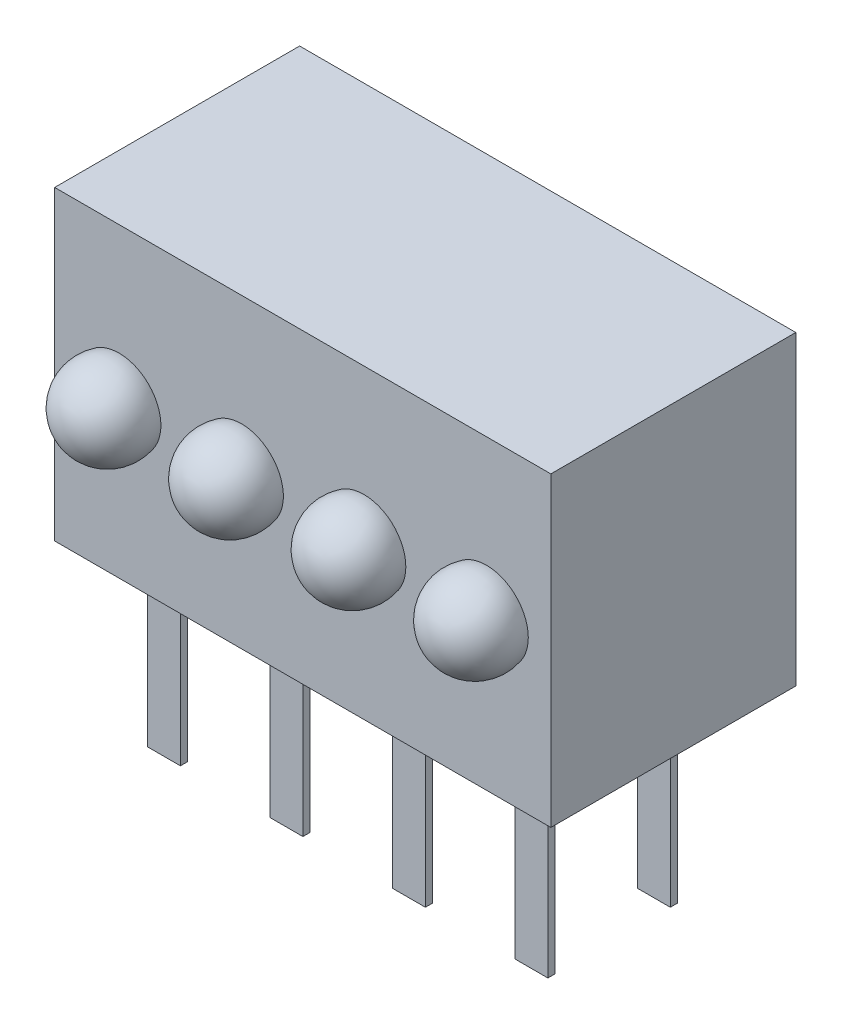
from build123d import *

# Parameters (mm, degrees)
SKETCH1_W          = 10.29
SKETCH1_H          = 5.08
EXTRUDE1_DEPTH     = 3.175
SKETCH2_W          = 0.686
SKETCH2_H          = 0.15
EXTRUDE2_DEPTH     = 3.68
SKETCH3_W          = 0.025316456
SKETCH3_H          = 0.026582278
CUT_EXTRUDE1_DEPTH = 0.01


with BuildPart() as part:
    # Sketch1 → Extrude1 (new body, symmetric)
    with BuildSketch(Plane(origin=(0, 0, 0), x_dir=(1, 0, 0), z_dir=(0, 1, 0))):
        Rectangle(SKETCH1_W, SKETCH1_H)
    extrude(amount=EXTRUDE1_DEPTH, both=True)

    # Sketch1_3 → Revolve1 (revolve)
    with BuildSketch(Plane(origin=(0, 0, 0), x_dir=(1, 0, 0), z_dir=(0, 1, 0)), mode=Mode.PRIVATE) as revolve1_sk:
        with BuildLine():
            Line((-2.942590062, -2.54), (-3.81, -2.54))
            Line((-3.81, -2.54), (-3.81, -3.68))
            ThreePointArc((-3.81, -3.68), (-3.093759817, -3.324977064), (-2.942590062, -2.54))
        make_face()
    revolve(revolve1_sk.sketch.rotate(Axis((-3.81, 0, 2.54), (0, 0, 1)), 180), axis=Axis((-3.81, 0, 2.54), (0, 0, 1)))  # turned: the seam where the file's is

    # Sketch1_4 → Revolve2 (revolve)
    with BuildSketch(Plane(origin=(0, 0, 0), x_dir=(1, 0, 0), z_dir=(0, 1, 0)), mode=Mode.PRIVATE) as revolve2_sk:
        with BuildLine():
            Line((-0.402590062, -2.54), (-1.27, -2.54))
            Line((-1.27, -2.54), (-1.27, -3.68))
            ThreePointArc((-1.27, -3.68), (-0.553759817, -3.324977064), (-0.402590062, -2.54))
        make_face()
    revolve(revolve2_sk.sketch.rotate(Axis((-1.27, 0, 2.54), (0, 0, 1)), 180), axis=Axis((-1.27, 0, 2.54), (0, 0, 1)))  # turned: the seam where the file's is

    # Sketch1_5 → Revolve3 (revolve)
    with BuildSketch(Plane(origin=(0, 0, 0), x_dir=(1, 0, 0), z_dir=(0, 1, 0))):
        with BuildLine():
            ThreePointArc((1.27, -3.68), (1.986240183, -3.324977064), (2.137409938, -2.54))
            Line((2.137409938, -2.54), (1.27, -2.54))
            Line((1.27, -2.54), (1.27, -3.68))
        make_face()
    revolve(axis=Axis((1.27, 0, 2.54), (0, 0, 1)))

    # Sketch1_6 → Revolve4 (revolve)
    with BuildSketch(Plane(origin=(0, 0, 0), x_dir=(1, 0, 0), z_dir=(0, 1, 0))):
        with BuildLine():
            ThreePointArc((3.81, -3.68), (4.526240183, -3.324977064), (4.677409938, -2.54))
            Line((4.677409938, -2.54), (3.81, -2.54))
            Line((3.81, -2.54), (3.81, -3.68))
        make_face()
    revolve(axis=Axis((3.81, 0, 2.54), (0, 0, 1)))

    # Sketch2 → Extrude2 (add)
    with BuildSketch(Plane.XZ.offset(3.175)):
        with Locations((-3.825, -1.02)):
            Rectangle(SKETCH2_W, SKETCH2_H)
        with Locations((-1.285, -1.02)):
            Rectangle(SKETCH2_W, SKETCH2_H)
        with Locations((1.255, -1.02)):
            Rectangle(SKETCH2_W, SKETCH2_H)
        with Locations((3.795, -1.02)):
            Rectangle(SKETCH2_W, SKETCH2_H)
        with Locations((3.795, 1.52)):
            Rectangle(SKETCH2_W, SKETCH2_H)
        with Locations((1.255, 1.52)):
            Rectangle(SKETCH2_W, SKETCH2_H)
        with Locations((-1.285, 1.52)):
            Rectangle(SKETCH2_W, SKETCH2_H)
        with Locations((-3.825, 1.52)):
            Rectangle(SKETCH2_W, SKETCH2_H)
    extrude(amount=EXTRUDE2_DEPTH)

    # Sketch3 → Cut-Extrude1 (cut)
    with BuildSketch(Plane.XZ.offset(3.175)):
        Polygon((-0.572151899, -1.949554214), (-0.595609177, -2.024237758), (-0.620352057, -2.024237758), (-0.636768196, -1.973901524), (-0.652294304, -2.024237758), (-0.678026108, -2.024237758), (-0.701265823, -1.949554214), (-0.676087816, -1.949554214), (-0.663093354, -2.0010376), (-0.646677215, -1.949554214), (-0.625178006, -1.949554214), (-0.608860759, -2.0010376), (-0.596044304, -1.949554214), align=None)
        Polygon((-0.437974684, -1.949554214), (-0.461431962, -2.024237758), (-0.486174842, -2.024237758), (-0.502590981, -1.973901524), (-0.518117089, -2.024237758), (-0.543848892, -2.024237758), (-0.567088608, -1.949554214), (-0.541910601, -1.949554214), (-0.528916139, -2.0010376), (-0.5125, -1.949554214), (-0.491000791, -1.949554214), (-0.474683544, -2.0010376), (-0.461867089, -1.949554214), align=None)
        Polygon((-0.303797468, -1.949554214), (-0.327254747, -2.024237758), (-0.351997627, -2.024237758), (-0.368413766, -1.973901524), (-0.383939873, -2.024237758), (-0.409671677, -2.024237758), (-0.432911392, -1.949554214), (-0.407733386, -1.949554214), (-0.394738924, -2.0010376), (-0.378322785, -1.949554214), (-0.356823576, -1.949554214), (-0.340506329, -2.0010376), (-0.327689873, -1.949554214), align=None)
        with Locations((-0.275949367, -2.010946619)):
            Rectangle(SKETCH3_W, SKETCH3_H)
        with BuildLine():
            add(Edge.make_bspline(
                [(-0.159493671, -1.993066872), (-0.15953016, -1.994289014), (-0.159601812, -1.996688892), (-0.16021153, -2.00019647), (-0.161205016, -2.003521175), (-0.162579134, -2.006683836), (-0.164367936, -2.009662454), (-0.166577526, -2.012442731), (-0.169141939, -2.015077531), (-0.172108149, -2.017483662), (-0.175388259, -2.019688038), (-0.178985835, -2.021585037), (-0.182864539, -2.02318152), (-0.187013125, -2.024520072), (-0.191459564, -2.025508652), (-0.196177094, -2.026232598), (-0.201170512, -2.026705927), (-0.20459409, -2.026747894), (-0.206348892, -2.026769404)],
                knots=[0, 0, 0, 0, 0.907352243, 1.781736951, 2.63548328, 3.47985091, 4.336556021, 5.208523475, 6.112432747, 7.062451073, 8.040435374, 9.043840564, 10.077958095, 11.152835584, 12.277940427, 13.457536469, 14.696825396, 16, 16, 16, 16], degree=3))
            add(Edge.make_bspline(
                [(-0.206348892, -2.026769404), (-0.208367148, -2.026745332), (-0.21227633, -2.026698708), (-0.217939855, -2.026270109), (-0.223207892, -2.025623969), (-0.228103607, -2.024657427), (-0.232708206, -2.023456662), (-0.237141474, -2.022165371), (-0.241422786, -2.020700955), (-0.244195876, -2.019600797), (-0.24556962, -2.019055796)],
                knots=[0, 0, 0, 0, 1.203215828, 2.33052265, 3.384689099, 4.366106119, 5.303329643, 6.221311756, 7.118865988, 8, 8, 8, 8], degree=3))
            Line((-0.24556962, -2.019055796), (-0.24556962, -1.995123834))
            Line((-0.24556962, -1.995123834), (-0.242721519, -1.995123834))
            add(Edge.make_bspline(
                [(-0.242721519, -1.995123834), (-0.241356205, -1.996205289), (-0.238633592, -1.99836185), (-0.234200359, -2.001124455), (-0.229552713, -2.003526618), (-0.224707243, -2.00550062), (-0.219810398, -2.007086944), (-0.21493502, -2.008180472), (-0.210169433, -2.008927821), (-0.207010864, -2.009008327), (-0.205458861, -2.009047885)],
                knots=[0, 0, 0, 0, 1.030622468, 2.055194264, 3.087043286, 4.125157485, 5.149848264, 6.130935704, 7.081611712, 8, 8, 8, 8], degree=3))
            add(Edge.make_bspline(
                [(-0.205458861, -2.009047885), (-0.205030085, -2.009046961), (-0.204112108, -2.009044984), (-0.202650581, -2.008917257), (-0.20099877, -2.00882168), (-0.199226261, -2.008614496), (-0.197429535, -2.008392635), (-0.195767134, -2.00801771), (-0.194257539, -2.007652843), (-0.193351018, -2.007284846), (-0.192919304, -2.007109594)],
                knots=[0, 0, 0, 0, 0.806402781, 1.726445712, 2.758724871, 3.919014682, 5.083870887, 6.16165551, 7.124521387, 8, 8, 8, 8], degree=3))
            add(Edge.make_bspline(
                [(-0.192919304, -2.007109594), (-0.192439741, -2.006881452), (-0.191497298, -2.006433105), (-0.190203698, -2.005622786), (-0.189036018, -2.004739321), (-0.187978647, -2.00377439), (-0.187104366, -2.00260864), (-0.186480499, -2.001199968), (-0.186135606, -1.99955095), (-0.186096583, -1.998375747), (-0.186075949, -1.997754372)],
                knots=[0, 0, 0, 0, 1.024747072, 2.013846092, 2.940605744, 3.850156746, 4.769278501, 5.73222711, 6.800942666, 8, 8, 8, 8], degree=3))
            add(Edge.make_bspline(
                [(-0.186075949, -1.997754372), (-0.186107794, -1.997208735), (-0.18617041, -1.996135851), (-0.186747603, -1.994600737), (-0.187657041, -1.993191568), (-0.188938631, -1.991922794), (-0.190531807, -1.99077326), (-0.192474191, -1.989790955), (-0.194724312, -1.988917767), (-0.196368382, -1.988499789), (-0.197231013, -1.98828048)],
                knots=[0, 0, 0, 0, 0.82557554, 1.623324704, 2.456147571, 3.35491006, 4.343819762, 5.427079081, 6.650009487, 8, 8, 8, 8], degree=3))
            add(Edge.make_bspline(
                [(-0.197231013, -1.98828048), (-0.199199639, -1.98783224), (-0.203238649, -1.986912589), (-0.209388473, -1.985773835), (-0.215516824, -1.984498975), (-0.219469591, -1.983292332), (-0.221400316, -1.982702948)],
                knots=[0, 0, 0, 0, 0.976100998, 2.002656142, 3.024398856, 4, 4, 4, 4], degree=3))
            add(Edge.make_bspline(
                [(-0.221400316, -1.982702948), (-0.222438835, -1.982349958), (-0.224460408, -1.98166283), (-0.227351919, -1.98050117), (-0.230013147, -1.979231341), (-0.23245286, -1.977875786), (-0.234653549, -1.976403246), (-0.236647817, -1.974861868), (-0.238410933, -1.973221828), (-0.239957738, -1.971482062), (-0.241282641, -1.969631359), (-0.242435025, -1.967686162), (-0.243417646, -1.965630742), (-0.244195684, -1.963460519), (-0.244820323, -1.961186864), (-0.245239305, -1.958809152), (-0.245538322, -1.956326023), (-0.245559046, -1.954631638), (-0.24556962, -1.953767031)],
                knots=[0, 0, 0, 0, 1.287047841, 2.5053592, 3.654260482, 4.74538952, 5.777514103, 6.75871007, 7.700244599, 8.599107454, 9.48590269, 10.366941872, 11.24940663, 12.154970331, 13.068988358, 14.012872203, 14.986013017, 16, 16, 16, 16], degree=3))
            add(Edge.make_bspline(
                [(-0.24556962, -1.953767031), (-0.245532318, -1.952610886), (-0.245458909, -1.950335614), (-0.24485748, -1.947006569), (-0.24383089, -1.943857833), (-0.242444827, -1.94085437), (-0.240616199, -1.938041284), (-0.238431404, -1.935362736), (-0.235807357, -1.932891145), (-0.232830235, -1.930590811), (-0.229542851, -1.928511412), (-0.226003867, -1.926680856), (-0.222234578, -1.925144205), (-0.218249032, -1.923870311), (-0.214030563, -1.92291564), (-0.20959333, -1.922196708), (-0.204919541, -1.921783526), (-0.20172812, -1.921732276), (-0.200098892, -1.921706113)],
                knots=[0, 0, 0, 0, 0.894990994, 1.761326291, 2.609044902, 3.454222546, 4.315366365, 5.200560057, 6.125081389, 7.100429509, 8.110379559, 9.133447974, 10.182136699, 11.259192205, 12.370181258, 13.528580438, 14.738335141, 16, 16, 16, 16], degree=3))
            add(Edge.make_bspline(
                [(-0.200098892, -1.921706113), (-0.198430198, -1.921728266), (-0.19509564, -1.921772534), (-0.1901143, -1.922151091), (-0.185159872, -1.922703402), (-0.180297448, -1.923552643), (-0.175605285, -1.924520875), (-0.17118617, -1.925620148), (-0.167106618, -1.926857654), (-0.164532965, -1.927812056), (-0.163291139, -1.928272569)],
                knots=[0, 0, 0, 0, 1.065407564, 2.129008667, 3.188544425, 4.247469455, 5.279542408, 6.247502114, 7.154394069, 8, 8, 8, 8], degree=3))
            Line((-0.163291139, -1.928272569), (-0.163291139, -1.950820037))
            Line((-0.163291139, -1.950820037), (-0.166119462, -1.950820037))
            add(Edge.make_bspline(
                [(-0.166119462, -1.950820037), (-0.167192966, -1.950020749), (-0.169383743, -1.948389584), (-0.173033347, -1.946287848), (-0.177000967, -1.944347757), (-0.181282594, -1.9426561), (-0.185742374, -1.941198093), (-0.190325133, -1.940178535), (-0.194951348, -1.939536827), (-0.198053052, -1.939464038), (-0.19960443, -1.939427632)],
                knots=[0, 0, 0, 0, 0.892265782, 1.820912499, 2.804518821, 3.836954028, 4.889985052, 5.931488012, 6.965393252, 8, 8, 8, 8], degree=3))
            add(Edge.make_bspline(
                [(-0.19960443, -1.939427632), (-0.200700035, -1.939449534), (-0.202897679, -1.939493468), (-0.20616687, -1.939878354), (-0.209407348, -1.940517207), (-0.21144203, -1.941333258), (-0.212460443, -1.941741714)],
                knots=[0, 0, 0, 0, 0.999122297, 2.004111588, 3.001004448, 4, 4, 4, 4], degree=3))
            add(Edge.make_bspline(
                [(-0.212460443, -1.941741714), (-0.212894173, -1.941942893), (-0.213761342, -1.942345117), (-0.214968884, -1.943124742), (-0.216089856, -1.944041086), (-0.217085439, -1.945093843), (-0.217929873, -1.946262197), (-0.218548899, -1.947529779), (-0.218923392, -1.948893661), (-0.218965739, -1.94982876), (-0.218987342, -1.950305796)],
                knots=[0, 0, 0, 0, 1.004925302, 2.009180302, 3.014392739, 4.04465309, 5.049195417, 6.035570224, 6.99785458, 8, 8, 8, 8], degree=3))
            add(Edge.make_bspline(
                [(-0.218987342, -1.950305796), (-0.218952904, -1.950943962), (-0.218887095, -1.952163437), (-0.218280511, -1.953879233), (-0.217295678, -1.955357667), (-0.216135073, -1.956352587), (-0.215017943, -1.957050025), (-0.213982284, -1.957560536), (-0.212773057, -1.958043895), (-0.211401809, -1.958541363), (-0.209865482, -1.959032551), (-0.208156925, -1.959508097), (-0.206274208, -1.959957393), (-0.204958333, -1.960243584), (-0.204272152, -1.960392822)],
                knots=[0, 0, 0, 0, 1.173816843, 2.243057204, 3.312297565, 4.415174738, 5.03266065, 5.73970059, 6.541434878, 7.433956553, 8.430083051, 9.515931566, 10.70464786, 12, 12, 12, 12], degree=3))
            add(Edge.make_bspline(
                [(-0.204272152, -1.960392822), (-0.202439229, -1.960768266), (-0.198844263, -1.961504637), (-0.193445039, -1.962617003), (-0.187940051, -1.963882362), (-0.184268899, -1.965034358), (-0.182357595, -1.965634119)],
                knots=[0, 0, 0, 0, 0.995749986, 1.952994291, 2.934271555, 4, 4, 4, 4], degree=3))
            add(Edge.make_bspline(
                [(-0.182357595, -1.965634119), (-0.181411107, -1.965953478), (-0.179559623, -1.966578196), (-0.176918075, -1.96766288), (-0.174469022, -1.968844969), (-0.172190751, -1.970067455), (-0.17012867, -1.971430672), (-0.168235447, -1.972845319), (-0.166552428, -1.974373428), (-0.165054478, -1.975986286), (-0.163736077, -1.977696718), (-0.162601114, -1.979534821), (-0.161637968, -1.98148935), (-0.160829836, -1.983562422), (-0.16025182, -1.98576949), (-0.159817762, -1.98809579), (-0.15952694, -1.990541106), (-0.159504884, -1.992215552), (-0.159493671, -1.993066872)],
                knots=[0, 0, 0, 0, 1.237386967, 2.420528625, 3.534815053, 4.605870898, 5.620827102, 6.594482803, 7.531295079, 8.432978826, 9.318460435, 10.202471551, 11.10474705, 12.014900263, 12.954095338, 13.926516828, 14.945802342, 16, 16, 16, 16], degree=3))
        make_face()
        with BuildLine():
            Line((-0.067088608, -2.024237758), (-0.091139241, -2.024237758))
            Line((-0.091139241, -2.024237758), (-0.091139241, -2.01640548))
            add(Edge.make_bspline(
                [(-0.091139241, -2.01640548), (-0.092232496, -2.017214147), (-0.094340276, -2.018773246), (-0.097514015, -2.02085201), (-0.100542736, -2.022635172), (-0.103464337, -2.024177325), (-0.106479693, -2.025368172), (-0.109707195, -2.026190028), (-0.113209459, -2.026691148), (-0.115636434, -2.026742739), (-0.116890823, -2.026769404)],
                knots=[0, 0, 0, 0, 1.150906677, 2.218931226, 3.20955724, 4.125565256, 5.012676028, 5.946647191, 6.938718366, 8, 8, 8, 8], degree=3))
            add(Edge.make_bspline(
                [(-0.116890823, -2.026769404), (-0.117907168, -2.026746675), (-0.119886286, -2.026702415), (-0.122763616, -2.026357677), (-0.125470927, -2.025819531), (-0.127987077, -2.025013675), (-0.130352422, -2.024039558), (-0.132503941, -2.022780471), (-0.13449163, -2.021321134), (-0.136295007, -2.019644198), (-0.137885627, -2.017723236), (-0.139272677, -2.015600485), (-0.140448489, -2.013265847), (-0.141390127, -2.01071448), (-0.142145061, -2.007956036), (-0.142669038, -2.004976829), (-0.142989618, -2.00178969), (-0.143021559, -1.999594561), (-0.143037975, -1.998466398)],
                knots=[0, 0, 0, 0, 1.108935798, 2.159418225, 3.158520219, 4.116592843, 5.038730546, 5.944611115, 6.829677354, 7.725673622, 8.624842385, 9.544872214, 10.487719724, 11.471363217, 12.50822837, 13.604887271, 14.769056852, 16, 16, 16, 16], degree=3))
            Line((-0.143037975, -1.998466398), (-0.143037975, -1.949554214))
            Line((-0.143037975, -1.949554214), (-0.118987342, -1.949554214))
            Line((-0.118987342, -1.949554214), (-0.118987342, -1.987133328))
            add(Edge.make_bspline(
                [(-0.118987342, -1.987133328), (-0.118985706, -1.988049799), (-0.118982576, -1.989804015), (-0.118900237, -1.992309821), (-0.118779336, -1.994577994), (-0.118640631, -1.996620022), (-0.118387615, -1.998466773), (-0.118009906, -2.000132934), (-0.11753908, -2.001652536), (-0.117074761, -2.002559238), (-0.116851266, -2.00299567)],
                knots=[0, 0, 0, 0, 1.361401701, 2.605856924, 3.723918663, 4.735739235, 5.645738665, 6.489217889, 7.27279937, 8, 8, 8, 8], degree=3))
            add(Edge.make_bspline(
                [(-0.116851266, -2.00299567), (-0.116621226, -2.003394318), (-0.116168987, -2.004178025), (-0.115249176, -2.005185173), (-0.114173193, -2.006022079), (-0.112903555, -2.006694723), (-0.111410474, -2.007178427), (-0.109678473, -2.007525174), (-0.107692458, -2.007738997), (-0.106283538, -2.007767159), (-0.105537975, -2.007782062)],
                knots=[0, 0, 0, 0, 0.849057291, 1.669173542, 2.503217716, 3.359509317, 4.311793648, 5.394940091, 6.621469141, 8, 8, 8, 8], degree=3))
            add(Edge.make_bspline(
                [(-0.105537975, -2.007782062), (-0.10499671, -2.007764605), (-0.103883832, -2.007728711), (-0.102178621, -2.007498783), (-0.100389592, -2.007137127), (-0.097875395, -2.006478103), (-0.09469925, -2.005298925), (-0.092335111, -2.003940123), (-0.091139241, -2.00325279)],
                knots=[0, 0, 0, 0, 0.638164724, 1.312110757, 2.025558264, 2.789159289, 4.375836335, 6, 6, 6, 6], degree=3))
            Line((-0.091139241, -2.00325279), (-0.091139241, -1.949554214))
            Line((-0.091139241, -1.949554214), (-0.067088608, -1.949554214))
            Line((-0.067088608, -1.949554214), (-0.067088608, -2.024237758))
        make_face()
        with BuildLine():
            Line((0.030379747, -2.024237758), (0.006329114, -2.024237758))
            Line((0.006329114, -2.024237758), (0.006329114, -1.986658645))
            add(Edge.make_bspline(
                [(0.006329114, -1.986658645), (0.00630879, -1.985128171), (0.006268255, -1.982075759), (0.005934675, -1.978318983), (0.005600966, -1.975471193), (0.005224143, -1.973635126), (0.004793956, -1.97208679), (0.00438151, -1.971201052), (0.004193038, -1.970796303)],
                knots=[0, 0, 0, 0, 1.709235885, 3.408940626, 4.211008593, 4.910095588, 5.501954032, 6, 6, 6, 6], degree=3))
            add(Edge.make_bspline(
                [(0.004193038, -1.970796303), (0.00394861, -1.97039818), (0.003469373, -1.969617605), (0.002531558, -1.968605583), (0.001434909, -1.967769369), (0.000156185, -1.96710442), (-0.001328468, -1.966618522), (-0.003041142, -1.966231863), (-0.005027113, -1.966063302), (-0.006434481, -1.966028393), (-0.007179589, -1.96600991)],
                knots=[0, 0, 0, 0, 0.860145871, 1.686437142, 2.528070002, 3.393017362, 4.331453407, 5.402595683, 6.624848233, 8, 8, 8, 8], degree=3))
            add(Edge.make_bspline(
                [(-0.007179589, -1.96600991), (-0.008311478, -1.966066491), (-0.010622712, -1.966182024), (-0.013484003, -1.966895615), (-0.015810878, -1.967707913), (-0.017656499, -1.968482149), (-0.019573028, -1.969436775), (-0.020856452, -1.970163849), (-0.021518987, -1.970539182)],
                knots=[0, 0, 0, 0, 1.338419466, 2.732951426, 3.468143565, 4.254837763, 5.099104234, 6, 6, 6, 6], degree=3))
            Line((-0.021518987, -1.970539182), (-0.021518987, -2.024237758))
            Line((-0.021518987, -2.024237758), (-0.04556962, -2.024237758))
            Line((-0.04556962, -2.024237758), (-0.04556962, -1.949554214))
            Line((-0.04556962, -1.949554214), (-0.021518987, -1.949554214))
            Line((-0.021518987, -1.949554214), (-0.021518987, -1.957386493))
            add(Edge.make_bspline(
                [(-0.021518987, -1.957386493), (-0.02046175, -1.956580055), (-0.018403774, -1.955010276), (-0.015227022, -1.952976866), (-0.01215631, -1.95116701), (-0.009101788, -1.949654875), (-0.005977291, -1.948456275), (-0.00270966, -1.947640672), (0.000707053, -1.947097724), (0.003043726, -1.947047912), (0.004232595, -1.947022569)],
                knots=[0, 0, 0, 0, 1.126064518, 2.191951536, 3.19307265, 4.144813015, 5.076393104, 6.021983703, 6.993610568, 8, 8, 8, 8], degree=3))
            add(Edge.make_bspline(
                [(0.004232595, -1.947022569), (0.005228866, -1.947047958), (0.007173765, -1.947097521), (0.010008526, -1.947407231), (0.012679947, -1.947957895), (0.015172222, -1.948755725), (0.017514838, -1.949741338), (0.019676795, -1.950972848), (0.021668821, -1.952431288), (0.02349739, -1.954092229), (0.025127571, -1.955982187), (0.026547057, -1.95809856), (0.02771848, -1.960447289), (0.028727312, -1.962994425), (0.029461537, -1.965772196), (0.029987988, -1.968762962), (0.030338418, -1.971968144), (0.030365695, -1.974184044), (0.030379747, -1.975325575)],
                knots=[0, 0, 0, 0, 1.088441561, 2.124831547, 3.110816719, 4.062969431, 4.979391633, 5.88258537, 6.774334107, 7.671621258, 8.575503974, 9.49441354, 10.447872957, 11.437639084, 12.482478955, 13.580222388, 14.753440527, 16, 16, 16, 16], degree=3))
            Line((0.030379747, -1.975325575), (0.030379747, -2.024237758))
        make_face()
        Polygon((0.125316456, -2.024237758), (0.053164557, -2.024237758), (0.053164557, -1.924237758), (0.078481013, -1.924237758), (0.078481013, -2.005250417), (0.125316456, -2.005250417), align=None)
        Polygon((0.212658228, -2.024237758), (0.140506329, -2.024237758), (0.140506329, -1.924237758), (0.212658228, -1.924237758), (0.212658228, -1.9432251), (0.165822785, -1.9432251), (0.165822785, -1.960946619), (0.208860759, -1.960946619), (0.208860759, -1.979933961), (0.165822785, -1.979933961), (0.165822785, -2.005250417), (0.212658228, -2.005250417), align=None)
        with BuildLine():
            add(Edge.make_bspline(
                [(0.329113924, -1.974336651), (0.329094609, -1.97548434), (0.329056357, -1.977757226), (0.328761165, -1.981122032), (0.32823514, -1.984387708), (0.327555959, -1.987571956), (0.326633453, -1.990650884), (0.325551739, -1.993658461), (0.324242093, -1.996563955), (0.322737241, -1.999365389), (0.321087768, -2.002037492), (0.319313019, -2.004557701), (0.31746724, -2.006940919), (0.315477927, -2.009135813), (0.313398746, -2.011177832), (0.311223217, -2.013068646), (0.308918153, -2.014772077), (0.30731099, -2.015794961), (0.30650712, -2.016306588)],
                knots=[0, 0, 0, 0, 1.105570398, 2.18947457, 3.250358341, 4.290584537, 5.323553275, 6.344225964, 7.367641686, 8.3905646, 9.405808457, 10.390761353, 11.358902336, 12.307789878, 13.241960776, 14.165076779, 15.082208636, 16, 16, 16, 16], degree=3))
            add(Edge.make_bspline(
                [(0.30650712, -2.016306588), (0.305267899, -2.017018757), (0.302783134, -2.018446731), (0.298799188, -2.020114862), (0.294668069, -2.021522818), (0.290309515, -2.022571008), (0.285663167, -2.023299741), (0.28066851, -2.023862791), (0.275267382, -2.024163156), (0.2715325, -2.024212324), (0.269600475, -2.024237758)],
                knots=[0, 0, 0, 0, 0.896298978, 1.797171328, 2.70531317, 3.633678302, 4.606491125, 5.655688921, 6.787306437, 8, 8, 8, 8], degree=3))
            Line((0.269600475, -2.024237758), (0.234177215, -2.024237758))
            Line((0.234177215, -2.024237758), (0.234177215, -1.924237758))
            Line((0.234177215, -1.924237758), (0.270609177, -1.924237758))
            add(Edge.make_bspline(
                [(0.270609177, -1.924237758), (0.272587901, -1.924254454), (0.276404614, -1.924286657), (0.281915032, -1.924702626), (0.287013411, -1.925302145), (0.291697991, -1.926228837), (0.296006397, -1.927337488), (0.299937419, -1.928700524), (0.303549308, -1.930198796), (0.305728136, -1.931472544), (0.306784019, -1.932089815)],
                knots=[0, 0, 0, 0, 1.267192274, 2.444256634, 3.537982003, 4.553396635, 5.500903572, 6.385021601, 7.217363933, 8, 8, 8, 8], degree=3))
            add(Edge.make_bspline(
                [(0.306784019, -1.932089815), (0.307634972, -1.932626356), (0.309327097, -1.933693269), (0.311728312, -1.935475122), (0.313957739, -1.937431199), (0.316086242, -1.939483017), (0.318066056, -1.941685905), (0.319909269, -1.944024609), (0.321613036, -1.946502716), (0.323171192, -1.949112135), (0.324591277, -1.951842375), (0.325783356, -1.954714721), (0.326822718, -1.957697594), (0.327668801, -1.960796533), (0.32832513, -1.964013923), (0.328771214, -1.967351403), (0.329054647, -1.970804592), (0.329093999, -1.973149385), (0.329113924, -1.974336651)],
                knots=[0, 0, 0, 0, 0.964043478, 1.917004671, 2.862223898, 3.805158963, 4.749279098, 5.698713747, 6.657523689, 7.629652222, 8.610369353, 9.604453025, 10.607693792, 11.636365947, 12.681120053, 13.752669011, 14.862083412, 16, 16, 16, 16], degree=3))
        make_face()
        with BuildLine():
            add(Edge.make_bspline(
                [(0.302531646, -1.974178423), (0.302521175, -1.97337371), (0.302500636, -1.971795218), (0.302312313, -1.969479042), (0.302041725, -1.967252993), (0.301652591, -1.96510936), (0.301112159, -1.963059212), (0.300479977, -1.961097643), (0.299752887, -1.959218719), (0.298871957, -1.95744106), (0.297898133, -1.955732723), (0.296750689, -1.954147195), (0.295502338, -1.952634313), (0.294124055, -1.951206327), (0.292581114, -1.949900431), (0.290921012, -1.948670355), (0.289120654, -1.947542029), (0.287847665, -1.946881979), (0.287203323, -1.946547885)],
                knots=[0, 0, 0, 0, 1.152052275, 2.259818351, 3.325348653, 4.362224493, 5.376551665, 6.358740615, 7.312387502, 8.258104984, 9.197203025, 10.124507262, 11.056413058, 12.004389423, 12.961766972, 13.947352551, 14.961020569, 16, 16, 16, 16], degree=3))
            add(Edge.make_bspline(
                [(0.287203323, -1.946547885), (0.286528425, -1.946241173), (0.285190731, -1.945633248), (0.283119908, -1.944902056), (0.281030524, -1.94432922), (0.278828925, -1.943898362), (0.276359165, -1.943576431), (0.273433583, -1.943379173), (0.269977674, -1.943237003), (0.267490959, -1.943229252), (0.266159019, -1.9432251)],
                knots=[0, 0, 0, 0, 0.826967603, 1.639107464, 2.447640171, 3.242670507, 4.14065217, 5.225198036, 6.513753944, 8, 8, 8, 8], degree=3))
            Line((0.266159019, -1.9432251), (0.259493671, -1.9432251))
            Line((0.259493671, -1.9432251), (0.259493671, -2.005250417))
            Line((0.259493671, -2.005250417), (0.266159019, -2.005250417))
            add(Edge.make_bspline(
                [(0.266159019, -2.005250417), (0.266917226, -2.005245671), (0.268380993, -2.005236509), (0.27049723, -2.005193395), (0.272463046, -2.005146681), (0.274267852, -2.005029644), (0.275920195, -2.004959144), (0.277406342, -2.004775473), (0.278743292, -2.004640998), (0.280315773, -2.004363276), (0.28217096, -2.0039573), (0.284337749, -2.003274143), (0.286478448, -2.002424568), (0.287866999, -2.001739489), (0.288568038, -2.001393613)],
                knots=[0, 0, 0, 0, 1.186805873, 2.291202465, 3.313317863, 4.264127762, 5.122212376, 5.900577546, 6.607154111, 7.224697658, 8.398873738, 9.57716935, 10.776782771, 12, 12, 12, 12], degree=3))
            add(Edge.make_bspline(
                [(0.288568038, -2.001393613), (0.289153152, -2.001052095), (0.290307072, -2.000378577), (0.291930612, -1.999244527), (0.293438202, -1.998036717), (0.294834679, -1.996748576), (0.296096265, -1.995359191), (0.297252353, -1.993899725), (0.29825774, -1.992339404), (0.299496994, -1.990150577), (0.300744084, -1.98712582), (0.301776483, -1.983153066), (0.302415631, -1.978794154), (0.302491983, -1.975756414), (0.302531646, -1.974178423)],
                knots=[0, 0, 0, 0, 0.755237594, 1.489427721, 2.205882609, 2.908165467, 3.605466573, 4.296695275, 4.981837198, 5.673065901, 7.099889822, 8.61390339, 10.241051878, 12, 12, 12, 12], degree=3))
        make_face(mode=Mode.SUBTRACT)
        with Locations((0.360759494, -2.010946619)):
            Rectangle(SKETCH3_W, SKETCH3_H)
        with BuildLine():
            add(Edge.make_bspline(
                [(0.435403481, -2.026769404), (0.433813364, -2.026747601), (0.43069222, -2.026704805), (0.426120933, -2.026227776), (0.421755567, -2.02551048), (0.417609943, -2.024488161), (0.4136994, -2.023147642), (0.41004445, -2.021477635), (0.406627778, -2.01951044), (0.404565858, -2.017925543), (0.403540348, -2.017137284)],
                knots=[0, 0, 0, 0, 1.123701398, 2.205645569, 3.245398653, 4.249180969, 5.220497262, 6.163202923, 7.086456062, 8, 8, 8, 8], degree=3))
            add(Edge.make_bspline(
                [(0.403540348, -2.017137284), (0.402588713, -2.016282451), (0.400689124, -2.01457609), (0.398221497, -2.011605547), (0.396103421, -2.008316574), (0.394291165, -2.004724921), (0.392859214, -2.000805036), (0.391866679, -1.996555141), (0.391239075, -1.991997812), (0.391173123, -1.988849607), (0.391139241, -1.98723222)],
                knots=[0, 0, 0, 0, 0.916342154, 1.829140869, 2.758848968, 3.716597128, 4.708179637, 5.743612459, 6.840783343, 8, 8, 8, 8], degree=3))
            add(Edge.make_bspline(
                [(0.391139241, -1.98723222), (0.391178001, -1.985528993), (0.391253124, -1.982227913), (0.391916883, -1.977455726), (0.392986496, -1.973038045), (0.394524054, -1.968986137), (0.396454496, -1.965292945), (0.398718989, -1.961921111), (0.401339514, -1.958878186), (0.403346653, -1.957132747), (0.404351266, -1.956259119)],
                knots=[0, 0, 0, 0, 1.171797512, 2.271099083, 3.308930235, 4.294129479, 5.24602549, 6.17106565, 7.084581485, 8, 8, 8, 8], degree=3))
            add(Edge.make_bspline(
                [(0.404351266, -1.956259119), (0.40537705, -1.95549034), (0.407441008, -1.953943497), (0.410840547, -1.952048685), (0.41445276, -1.950444168), (0.418283877, -1.949198282), (0.422264395, -1.948249745), (0.426329936, -1.947522773), (0.430476303, -1.947102748), (0.433266488, -1.947049424), (0.434671677, -1.947022569)],
                knots=[0, 0, 0, 0, 0.952097844, 1.915695341, 2.885641886, 3.886921822, 4.905719434, 5.925883802, 6.95543633, 8, 8, 8, 8], degree=3))
            add(Edge.make_bspline(
                [(0.434671677, -1.947022569), (0.435918404, -1.947039532), (0.438369891, -1.947072889), (0.441970824, -1.947395546), (0.445419409, -1.94792571), (0.448716721, -1.948669304), (0.451889869, -1.949562103), (0.454949341, -1.950593384), (0.457914157, -1.951731325), (0.459814835, -1.95261554), (0.460759494, -1.953055005)],
                knots=[0, 0, 0, 0, 1.107671842, 2.178058178, 3.209662749, 4.206063564, 5.179815947, 6.137646632, 7.07438927, 8, 8, 8, 8], degree=3))
            Line((0.460759494, -1.953055005), (0.460759494, -1.973604847))
            Line((0.460759494, -1.973604847), (0.45741693, -1.973604847))
            add(Edge.make_bspline(
                [(0.45741693, -1.973604847), (0.456918162, -1.97318662), (0.455836226, -1.972279396), (0.454034874, -1.970878383), (0.451901363, -1.969327818), (0.450250156, -1.968441815), (0.449367089, -1.96796798)],
                knots=[0, 0, 0, 0, 0.792878214, 1.719922066, 2.780612869, 4, 4, 4, 4], degree=3))
            add(Edge.make_bspline(
                [(0.449367089, -1.96796798), (0.448439429, -1.967525111), (0.4465324, -1.966614688), (0.443972423, -1.965795145), (0.441783392, -1.965216608), (0.439971509, -1.964963798), (0.438038089, -1.96477345), (0.436702818, -1.964754055), (0.436016614, -1.964744088)],
                knots=[0, 0, 0, 0, 1.33256682, 2.739414054, 3.480190821, 4.267897792, 5.109861573, 6, 6, 6, 6], degree=3))
            add(Edge.make_bspline(
                [(0.436016614, -1.964744088), (0.435251065, -1.964763647), (0.433767468, -1.964801552), (0.431605865, -1.965078474), (0.429587789, -1.965557209), (0.427683381, -1.966195621), (0.425944635, -1.96709186), (0.424302105, -1.968104128), (0.422827629, -1.969358636), (0.421485682, -1.970776376), (0.420298198, -1.97236689), (0.419271446, -1.974093377), (0.418388719, -1.97595127), (0.417686826, -1.977949178), (0.417129316, -1.98007904), (0.416739751, -1.982341851), (0.416497972, -1.984741448), (0.416470029, -1.986387744), (0.416455696, -1.98723222)],
                knots=[0, 0, 0, 0, 1.087094245, 2.106738054, 3.087824582, 4.029427112, 4.95060567, 5.859714611, 6.763601524, 7.690850518, 8.627131371, 9.576106403, 10.539384251, 11.543302637, 12.578856349, 13.662518017, 14.800975475, 16, 16, 16, 16], degree=3))
            add(Edge.make_bspline(
                [(0.416455696, -1.98723222), (0.416470471, -1.988096377), (0.416499177, -1.989775389), (0.416732691, -1.992217), (0.417148582, -1.994498432), (0.41771983, -1.996623751), (0.418444178, -1.99858977), (0.419349295, -2.000387166), (0.420385652, -2.002043974), (0.42163021, -2.003506586), (0.422994093, -2.004822907), (0.424508985, -2.005959042), (0.426168224, -2.006907187), (0.427950405, -2.00771165), (0.429883445, -2.008290048), (0.431939982, -2.00872674), (0.434129537, -2.009015296), (0.435639891, -2.009036859), (0.436412184, -2.009047885)],
                knots=[0, 0, 0, 0, 1.230336593, 2.390482092, 3.487897344, 4.52859895, 5.520747884, 6.465347575, 7.38981449, 8.296085817, 9.192433006, 10.084246191, 10.984321635, 11.908883871, 12.862027947, 13.850751296, 14.901019963, 16, 16, 16, 16], degree=3))
            add(Edge.make_bspline(
                [(0.436412184, -2.009047885), (0.437138026, -2.009039662), (0.438553028, -2.00902363), (0.440611451, -2.008807564), (0.442565368, -2.008528237), (0.444399915, -2.008086961), (0.446104164, -2.007552077), (0.447669817, -2.00698125), (0.449082423, -2.00637697), (0.449943758, -2.005909355), (0.450356013, -2.005685543)],
                knots=[0, 0, 0, 0, 1.200879421, 2.341068892, 3.423000803, 4.465923194, 5.460027553, 6.378409259, 7.223869634, 8, 8, 8, 8], degree=3))
            add(Edge.make_bspline(
                [(0.450356013, -2.005685543), (0.451064369, -2.005257857), (0.452425742, -2.004435898), (0.454250861, -2.003015438), (0.455894986, -2.001608998), (0.456919091, -2.000652231), (0.45741693, -2.000187126)],
                knots=[0, 0, 0, 0, 1.105932972, 2.12546697, 3.088749538, 4, 4, 4, 4], degree=3))
            Line((0.45741693, -2.000187126), (0.460759494, -2.000187126))
            Line((0.460759494, -2.000187126), (0.460759494, -2.020895195))
            add(Edge.make_bspline(
                [(0.460759494, -2.020895195), (0.459814117, -2.021332737), (0.457923136, -2.022207927), (0.455008359, -2.023361077), (0.452015116, -2.024333957), (0.448963886, -2.025226303), (0.445794254, -2.025924498), (0.442476905, -2.026413728), (0.438995601, -2.026715467), (0.436617185, -2.02675118), (0.435403481, -2.026769404)],
                knots=[0, 0, 0, 0, 0.952024047, 1.90427691, 2.862762905, 3.827874523, 4.80891974, 5.826446878, 6.890837857, 8, 8, 8, 8], degree=3))
        make_face()
        with BuildLine():
            add(Edge.make_bspline(
                [(0.553164557, -1.986935543), (0.553139637, -1.988440375), (0.553091062, -1.991373696), (0.552554854, -1.995646516), (0.551731391, -1.999676958), (0.550598066, -2.003477795), (0.549080213, -2.007020841), (0.547237799, -2.010316795), (0.545064208, -2.013368978), (0.542573889, -2.016159204), (0.539772404, -2.018657396), (0.536698638, -2.020853589), (0.533328772, -2.022660637), (0.529720026, -2.024187187), (0.525830719, -2.025343288), (0.521671624, -2.026161238), (0.517254115, -2.02669557), (0.514215749, -2.026744382), (0.512658228, -2.026769404)],
                knots=[0, 0, 0, 0, 1.120122129, 2.18341868, 3.201215738, 4.181270334, 5.131540819, 6.065757527, 6.988093576, 7.916512302, 8.844931028, 9.778115023, 10.722851943, 11.686686084, 12.691660064, 13.738321946, 14.84062285, 16, 16, 16, 16], degree=3))
            add(Edge.make_bspline(
                [(0.512658228, -2.026769404), (0.51110068, -2.026744464), (0.508062261, -2.026695813), (0.503645127, -2.026160342), (0.499490907, -2.025347625), (0.495606256, -2.02417839), (0.491991945, -2.022666299), (0.488618118, -2.020852858), (0.485543936, -2.018657605), (0.482742733, -2.016159094), (0.480251696, -2.013369209), (0.478080692, -2.01031598), (0.476229753, -2.007026187), (0.47474936, -2.003468912), (0.473576829, -1.999681704), (0.472764049, -1.995645706), (0.472224732, -1.991373915), (0.472176594, -1.988440449), (0.472151899, -1.986935543)],
                knots=[0, 0, 0, 0, 1.159424321, 2.261770074, 3.308474541, 4.308788811, 5.277191138, 6.221966496, 7.15518846, 8.08364496, 9.01210146, 9.934475036, 10.868729753, 11.817121636, 12.798654016, 13.816492484, 14.879832297, 16, 16, 16, 16], degree=3))
            add(Edge.make_bspline(
                [(0.472151899, -1.986935543), (0.472177022, -1.98542412), (0.472226107, -1.982471109), (0.472761477, -1.978172236), (0.473579494, -1.974111586), (0.474739526, -1.970303273), (0.476255799, -1.966751673), (0.478096824, -1.963449568), (0.480293292, -1.960402993), (0.48280279, -1.957613242), (0.485614584, -1.955116861), (0.488708516, -1.952943955), (0.492060435, -1.951107298), (0.495667634, -1.949585464), (0.49955419, -1.948450899), (0.503691132, -1.947633321), (0.508088526, -1.947095248), (0.511107264, -1.947047236), (0.512658228, -1.947022569)],
                knots=[0, 0, 0, 0, 1.124034801, 2.196132384, 3.217834281, 4.203147447, 5.152578239, 6.085969439, 7.010345409, 7.941219594, 8.872481455, 9.802010446, 10.748267785, 11.711250247, 12.709230373, 13.754967386, 14.846549946, 16, 16, 16, 16], degree=3))
            add(Edge.make_bspline(
                [(0.512658228, -1.947022569), (0.514228972, -1.947047281), (0.517287148, -1.947095394), (0.521730477, -1.947631733), (0.525904607, -1.948444259), (0.529802216, -1.949612329), (0.533426224, -1.951115599), (0.5367734, -1.952970545), (0.539858359, -1.955144895), (0.542626621, -1.957674724), (0.54511038, -1.960469678), (0.547272736, -1.963527358), (0.549108213, -1.966834934), (0.550583955, -1.970396809), (0.551758158, -1.974189441), (0.552578569, -1.978223868), (0.553084721, -1.982498774), (0.553137483, -1.985430917), (0.553164557, -1.986935543)],
                knots=[0, 0, 0, 0, 1.167473013, 2.273023816, 3.322954552, 4.326451713, 5.293391623, 6.234801871, 7.166614545, 8.093305908, 9.017100806, 9.942078766, 10.872536262, 11.824015763, 12.804065898, 13.820367293, 14.881523901, 16, 16, 16, 16], degree=3))
        make_face()
        with BuildLine():
            add(Edge.make_bspline(
                [(0.523457278, -2.005428423), (0.523812024, -2.00492823), (0.524533974, -2.003910278), (0.525409914, -2.002215086), (0.526169567, -2.000383818), (0.526788254, -1.998357535), (0.527298396, -1.996059758), (0.527600016, -1.993402826), (0.527832831, -1.99036794), (0.527842811, -1.988215132), (0.527848101, -1.987073993)],
                knots=[0, 0, 0, 0, 0.765094823, 1.557058493, 2.376706509, 3.238810155, 4.199844458, 5.312104478, 6.575226644, 8, 8, 8, 8], degree=3))
            add(Edge.make_bspline(
                [(0.527848101, -1.987073993), (0.527830412, -1.985999111), (0.527796522, -1.983939755), (0.527610152, -1.980979992), (0.527261478, -1.978296565), (0.5267636, -1.975879169), (0.526153829, -1.973708481), (0.525427894, -1.971766119), (0.524589376, -1.970047517), (0.523903909, -1.969042285), (0.523575949, -1.968561334)],
                knots=[0, 0, 0, 0, 1.337076348, 2.561692668, 3.686680134, 4.69989255, 5.629188848, 6.488203485, 7.276684665, 8, 8, 8, 8], degree=3))
            add(Edge.make_bspline(
                [(0.523575949, -1.968561334), (0.523237376, -1.968123497), (0.522576126, -1.96726838), (0.521418372, -1.966164746), (0.520137891, -1.965286797), (0.518757044, -1.964618132), (0.517316335, -1.964104622), (0.515810213, -1.963748581), (0.514253653, -1.963527418), (0.513192974, -1.96349474), (0.512658228, -1.963478265)],
                knots=[0, 0, 0, 0, 1.058499091, 2.067300666, 3.047512573, 4.018335651, 4.996351322, 5.969796037, 6.97646375, 8, 8, 8, 8], degree=3))
            add(Edge.make_bspline(
                [(0.512658228, -1.963478265), (0.512130325, -1.963489295), (0.511097766, -1.963510869), (0.509594689, -1.963689386), (0.508179036, -1.963989384), (0.50683387, -1.96439357), (0.505548722, -1.965004946), (0.504317445, -1.965853764), (0.503102058, -1.966930344), (0.50236373, -1.967780679), (0.501977848, -1.9682251)],
                knots=[0, 0, 0, 0, 1.04189444, 2.037910168, 2.982338511, 3.896140384, 4.804271323, 5.778885192, 6.839150358, 8, 8, 8, 8], degree=3))
            add(Edge.make_bspline(
                [(0.501977848, -1.9682251), (0.501642414, -1.968698768), (0.500938424, -1.969692876), (0.500089235, -1.971413245), (0.499319936, -1.973358736), (0.498640648, -1.975549872), (0.498109463, -1.978017412), (0.497751274, -1.980776025), (0.497506594, -1.98382596), (0.497481478, -1.985959266), (0.497468354, -1.987073993)],
                knots=[0, 0, 0, 0, 0.70629823, 1.482341141, 2.329662943, 3.254583898, 4.274063958, 5.401087491, 6.641978366, 8, 8, 8, 8], degree=3))
            add(Edge.make_bspline(
                [(0.497468354, -1.987073993), (0.497474295, -1.988076732), (0.4974858, -1.990018863), (0.497727995, -1.992821195), (0.498014823, -1.995429639), (0.498501392, -1.997817692), (0.49907323, -2.000002869), (0.499821274, -2.001954462), (0.500644614, -2.003709535), (0.501344968, -2.004737275), (0.501681171, -2.005230638)],
                knots=[0, 0, 0, 0, 1.270983191, 2.461674417, 3.564986371, 4.596265355, 5.549463796, 6.425202083, 7.244022889, 8, 8, 8, 8], degree=3))
            add(Edge.make_bspline(
                [(0.501681171, -2.005230638), (0.502021533, -2.005647413), (0.502692579, -2.006469111), (0.503840375, -2.007545252), (0.505108347, -2.008419809), (0.506457966, -2.009142798), (0.507924557, -2.009677181), (0.509484843, -2.010047114), (0.511142292, -2.010266254), (0.512275179, -2.010297624), (0.512856013, -2.010313708)],
                knots=[0, 0, 0, 0, 1.010886179, 1.993025998, 2.945391046, 3.898964935, 4.863589088, 5.87059323, 6.908247091, 8, 8, 8, 8], degree=3))
            add(Edge.make_bspline(
                [(0.512856013, -2.010313708), (0.513863641, -2.010261186), (0.515861448, -2.010157053), (0.518276869, -2.009440647), (0.520078527, -2.008585668), (0.521333325, -2.007726259), (0.522471635, -2.006665491), (0.523124499, -2.005846089), (0.523457278, -2.005428423)],
                knots=[0, 0, 0, 0, 1.49343762, 2.961012893, 3.700518105, 4.446788108, 5.208294864, 6, 6, 6, 6], degree=3))
        make_face(mode=Mode.SUBTRACT)
        with BuildLine():
            Line((0.644303797, -1.970539182), (0.644303797, -2.024237758))
            Line((0.644303797, -2.024237758), (0.620253165, -2.024237758))
            Line((0.620253165, -2.024237758), (0.620253165, -1.986381746))
            add(Edge.make_bspline(
                [(0.620253165, -1.986381746), (0.620246898, -1.985491746), (0.620234875, -1.983784181), (0.620212363, -1.981323851), (0.620096991, -1.979076509), (0.620000439, -1.977029174), (0.619801755, -1.975172788), (0.619524083, -1.97349308), (0.619095228, -1.971990083), (0.618687802, -1.971088969), (0.61849288, -1.970657853)],
                knots=[0, 0, 0, 0, 1.33997484, 2.570892857, 3.703483919, 4.727540125, 5.655929516, 6.512630168, 7.288405602, 8, 8, 8, 8], degree=3))
            add(Edge.make_bspline(
                [(0.61849288, -1.970657853), (0.618282954, -1.970272486), (0.61786683, -1.969508593), (0.616998785, -1.968540732), (0.615990476, -1.967730087), (0.614810314, -1.967088633), (0.613431631, -1.96659047), (0.611816509, -1.966241125), (0.609952652, -1.966060723), (0.608630364, -1.966027485), (0.607931171, -1.96600991)],
                knots=[0, 0, 0, 0, 0.859345536, 1.703436662, 2.532498256, 3.390183975, 4.328249457, 5.402602062, 6.626559876, 8, 8, 8, 8], degree=3))
            add(Edge.make_bspline(
                [(0.607931171, -1.96600991), (0.607343832, -1.966033306), (0.606163857, -1.966080307), (0.604399742, -1.96632525), (0.602672133, -1.966820632), (0.600453045, -1.967658343), (0.597854183, -1.968882535), (0.595886252, -1.969999998), (0.594936709, -1.970539182)],
                knots=[0, 0, 0, 0, 0.759382397, 1.525614786, 2.294447385, 3.076151307, 4.589219126, 6, 6, 6, 6], degree=3))
            Line((0.594936709, -1.970539182), (0.594936709, -2.024237758))
            Line((0.594936709, -2.024237758), (0.570886076, -2.024237758))
            Line((0.570886076, -2.024237758), (0.570886076, -1.949554214))
            Line((0.570886076, -1.949554214), (0.594936709, -1.949554214))
            Line((0.594936709, -1.949554214), (0.594936709, -1.957386493))
            add(Edge.make_bspline(
                [(0.594936709, -1.957386493), (0.595957797, -1.956605113), (0.597940337, -1.95508799), (0.600953613, -1.953040661), (0.603906507, -1.951285077), (0.606799194, -1.949737182), (0.609752873, -1.948497567), (0.612851277, -1.947654627), (0.616094567, -1.947123555), (0.618312774, -1.94705664), (0.619442247, -1.947022569)],
                knots=[0, 0, 0, 0, 1.136109262, 2.205863928, 3.217041414, 4.170849475, 5.103496751, 6.040664374, 7.002340634, 8, 8, 8, 8], degree=3))
            add(Edge.make_bspline(
                [(0.619442247, -1.947022569), (0.620645481, -1.947054323), (0.62299712, -1.947116384), (0.626409162, -1.947785524), (0.629624607, -1.948790592), (0.632582226, -1.950279411), (0.635302424, -1.952120863), (0.637715584, -1.954377602), (0.639805479, -1.957044845), (0.64089703, -1.959050071), (0.641455696, -1.960076366)],
                knots=[0, 0, 0, 0, 1.065971563, 2.0833675, 3.072814207, 4.045738768, 5.009267307, 5.977487593, 6.964858173, 8, 8, 8, 8], degree=3))
            add(Edge.make_bspline(
                [(0.641455696, -1.960076366), (0.642637781, -1.959099401), (0.644941436, -1.957195486), (0.648495052, -1.954652863), (0.651974132, -1.952398306), (0.655414652, -1.950489481), (0.658815096, -1.948938927), (0.662197602, -1.94784494), (0.665544031, -1.947152576), (0.667771115, -1.947065488), (0.668868671, -1.947022569)],
                knots=[0, 0, 0, 0, 1.188147474, 2.315470194, 3.384102413, 4.399459064, 5.362307068, 6.27522031, 7.149990929, 8, 8, 8, 8], degree=3))
            add(Edge.make_bspline(
                [(0.668868671, -1.947022569), (0.669851921, -1.947045964), (0.671765063, -1.947091484), (0.67454762, -1.947426499), (0.677143805, -1.947998228), (0.679562078, -1.948787159), (0.681795216, -1.949819465), (0.683841647, -1.951095777), (0.685714647, -1.952581578), (0.687386566, -1.95430324), (0.688872492, -1.956227373), (0.690168729, -1.95836234), (0.691246883, -1.960702423), (0.692144985, -1.963236932), (0.692829098, -1.965973115), (0.693319166, -1.968916031), (0.693617377, -1.972055961), (0.693652749, -1.97421731), (0.693670886, -1.975325575)],
                knots=[0, 0, 0, 0, 1.099528869, 2.139389204, 3.128691273, 4.06836032, 4.978849901, 5.872980696, 6.759662307, 7.646067956, 8.55014577, 9.473266406, 10.433198647, 11.426668526, 12.476415665, 13.583140093, 14.760718182, 16, 16, 16, 16], degree=3))
            Line((0.693670886, -1.975325575), (0.693670886, -2.024237758))
            Line((0.693670886, -2.024237758), (0.669620253, -2.024237758))
            Line((0.669620253, -2.024237758), (0.669620253, -1.986381746))
            add(Edge.make_bspline(
                [(0.669620253, -1.986381746), (0.669614543, -1.985485129), (0.669603583, -1.983764334), (0.669573902, -1.981297981), (0.669484266, -1.979050164), (0.669403721, -1.977010272), (0.6692351, -1.975158139), (0.668948066, -1.973486489), (0.668517939, -1.971994501), (0.668126047, -1.971089577), (0.667939082, -1.970657853)],
                knots=[0, 0, 0, 0, 1.350843832, 2.592553583, 3.715618503, 4.739861077, 5.667890227, 6.515410335, 7.291728161, 8, 8, 8, 8], degree=3))
            add(Edge.make_bspline(
                [(0.667939082, -1.970657853), (0.667735705, -1.970272848), (0.667333047, -1.969510593), (0.666483935, -1.968535601), (0.665472098, -1.967725072), (0.664275171, -1.96708942), (0.662877515, -1.966590529), (0.661242699, -1.966241364), (0.659352701, -1.966060067), (0.658010647, -1.966027303), (0.657298259, -1.96600991)],
                knots=[0, 0, 0, 0, 0.84645005, 1.675850114, 2.498752818, 3.361341904, 4.304511378, 5.383432037, 6.611077598, 8, 8, 8, 8], degree=3))
            add(Edge.make_bspline(
                [(0.657298259, -1.96600991), (0.656297666, -1.96605836), (0.65427854, -1.966156127), (0.651790256, -1.966859098), (0.649774065, -1.96768874), (0.648078326, -1.96846197), (0.646237567, -1.969432392), (0.644967402, -1.970159369), (0.644303797, -1.970539182)],
                knots=[0, 0, 0, 0, 1.291070249, 2.605286939, 3.312383926, 4.109045945, 5.012060117, 6, 6, 6, 6], degree=3))
        make_face()
    extrude(amount=-CUT_EXTRUDE1_DEPTH, mode=Mode.SUBTRACT)


solid = part.part
